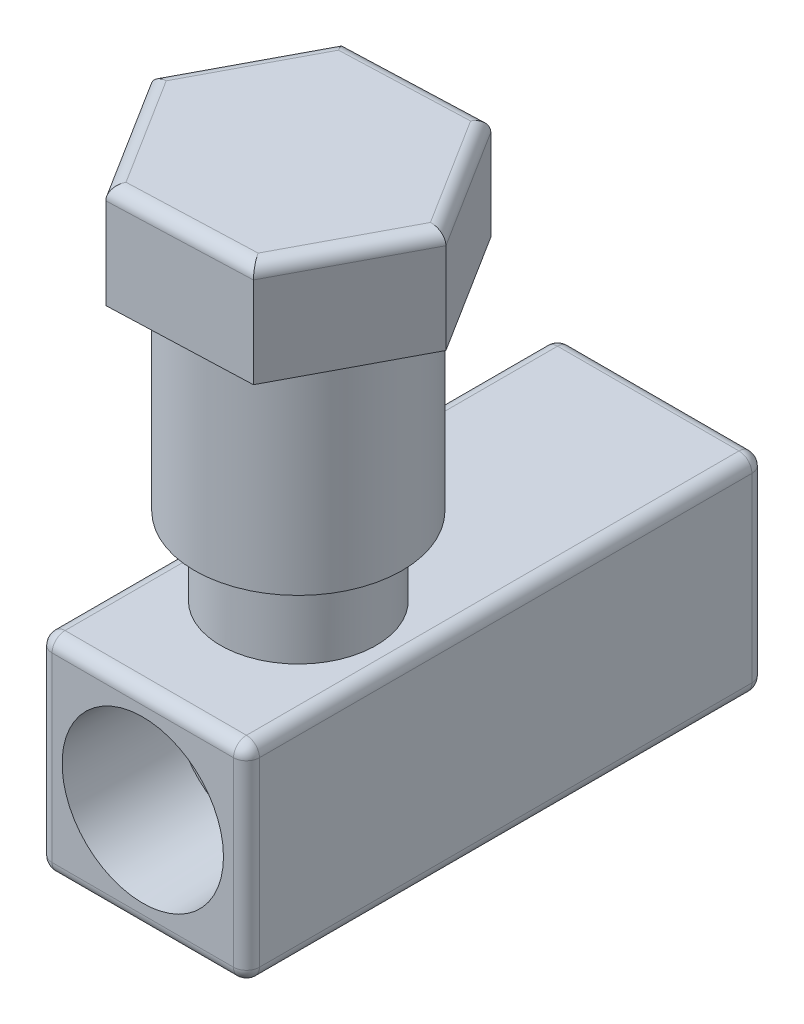
from build123d import *

# Parameters (mm, degrees)
SKETCH1_W           = 25.4
SKETCH1_H           = 25.4
BOSS_EXTRUDE1_DEPTH = 63.5
SKETCH4_R           = 9.525
BOSS_EXTRUDE2_DEPTH = 9.525
SKETCH5_R           = 12.7
BOSS_EXTRUDE3_DEPTH = 25.4
BOSS_EXTRUDE4_DEPTH = 12.7
FILLET1_R           = 1.5875


with BuildPart() as part:
    # Sketch1 → Boss-Extrude1 (new body)
    with BuildSketch(Plane.XY):
        with Locations((12.7, 12.7)):
            Rectangle(SKETCH1_W, SKETCH1_H)
    extrude(amount=BOSS_EXTRUDE1_DEPTH)

    # Sketch2 → 1/2 NPT Tapped Hole1 (revolve, cut)
    with BuildSketch(Plane(origin=(12.7, 12.7, 63.5), x_dir=(0, -1, 0), z_dir=(1, 0, 0))):
        Polygon((0, 0), (0, 27.970543693), (8.9281, 22.606), (8.9281, 13.462), (9.479726792, 13.462), (9.8827971, 0), align=None)
    revolve(axis=Axis((12.7, 12.7, 69.85), (0, 0, -1)), mode=Mode.SUBTRACT)

    # Sketch4 → Boss-Extrude2 (add)
    with BuildSketch(Plane(origin=(0, 25.4, 0), x_dir=(1, 0, 0), z_dir=(0, 1, 0))):
        with Locations((12.7, -44.45)):
            Circle(SKETCH4_R)
    extrude(amount=BOSS_EXTRUDE2_DEPTH)

    # Sketch5 → Boss-Extrude3 (add)
    with BuildSketch(Plane(origin=(0, 34.925, 0), x_dir=(1, 0, 0), z_dir=(0, 1, 0))):
        with Locations((12.7, -44.45)):
            Circle(SKETCH5_R)
    extrude(amount=BOSS_EXTRUDE3_DEPTH)

    # Sketch6 → Boss-Extrude4 (add)
    with BuildSketch(Plane(origin=(0, 60.325, 0), x_dir=(1, 0, 0), z_dir=(0, 1, 0))):
        Polygon((3.422327472, -29.674263649), (-4.734999304, -45.096831921), (4.542673224, -59.872568273), (21.977672528, -59.225736351), (30.134999304, -43.803168079), (20.857326776, -29.027431727), align=None)
    extrude(amount=BOSS_EXTRUDE4_DEPTH)

    # Sketch7 → 1/2 NPT Tapped Hole2 (revolve, cut)
    with BuildSketch(Plane(origin=(12.7, 12.7, 0), x_dir=(0, 1, 0), z_dir=(1, 0, 0))):
        Polygon((0, 0), (0, 27.970543693), (8.9281, 22.606), (8.9281, 13.462), (9.479726792, 13.462), (9.8827971, 0), align=None)
    revolve(axis=Axis((12.7, 12.7, -6.35), (0, 0, 1)), mode=Mode.SUBTRACT)

    # Fillet1
    fillet1_edges = [part.edges().sort_by_distance(p)[0] for p in [
        (25.4, 12.7, 63.5),
        (12.7, 25.4, 63.5),
        (12.139827124, 73.025, 29.350847688),
        (-0.656335916, 73.025, 37.385547785),
        (-0.09616304, 73.025, 52.484700097),
        (13.260172876, 73.025, 59.549152312),
        (26.056335916, 73.025, 51.514452215),
        (25.49616304, 73.025, 36.415299903),
        (0, 12.7, 63.5),
        (12.7, 25.4, 0),
        (25.4, 12.7, 0),
        (12.7, 0, 0),
        (0, 12.7, 0),
        (12.7, 0, 63.5),
        (0, 25.4, 31.75),
        (25.4, 25.4, 31.75),
        (25.4, 0, 31.75),
        (0, 0, 31.75),
    ]]
    fillet(fillet1_edges, radius=FILLET1_R)


solid = part.part
